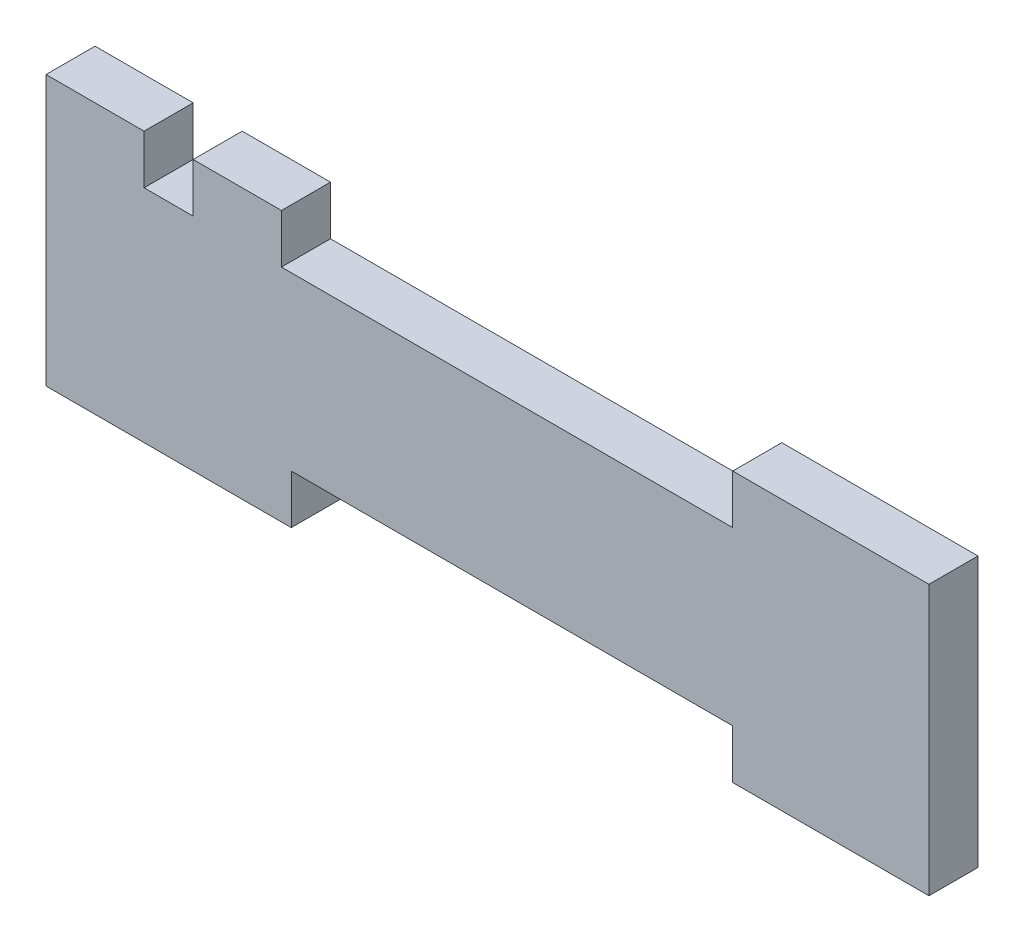
from build123d import *

# Parameters (mm, degrees)
SKETCH1_W           = 10
SKETCH1_H           = 5
SKETCH1_W_2         = 25
SKETCH1_W_3         = 20
BOSS_EXTRUDE1_DEPTH = 5
SKETCH2_W           = 5
SKETCH2_H           = 5
CUT_EXTRUDE1_DEPTH  = 1


with BuildPart() as part:
    # Sketch1 → Boss-Extrude1 (new body)
    with BuildSketch(Plane.XY):
        Polygon((-20, 0), (0, 0), (0, 17.5), (-20, 17.5), (-65, 17.5), (-75, 17.5), (-80, 17.5), (-90, 17.5), (-90, 0), (-65, 0), align=None)
        with Locations((-85, 20)):
            Rectangle(SKETCH1_W, SKETCH1_H)
        with Locations((-70, 20)):
            Rectangle(SKETCH1_W, SKETCH1_H)
        with Locations((-77.5, -2.5)):
            Rectangle(SKETCH1_W_2, SKETCH1_H)
        with Locations((-10, -2.5)):
            Rectangle(SKETCH1_W_3, SKETCH1_H)
        with Locations((-10, 20)):
            Rectangle(SKETCH1_W_3, SKETCH1_H)
    extrude(amount=BOSS_EXTRUDE1_DEPTH)

    # Sketch2 → Cut-Extrude1 (cut)
    with BuildSketch(Plane(origin=(-65, 0, 0), x_dir=(0, 0, -1), z_dir=(1, 0, 0))):
        with Locations((-2.5, 20)):
            Rectangle(SKETCH2_W, SKETCH2_H)
    extrude(amount=-CUT_EXTRUDE1_DEPTH, mode=Mode.SUBTRACT)


solid = part.part
